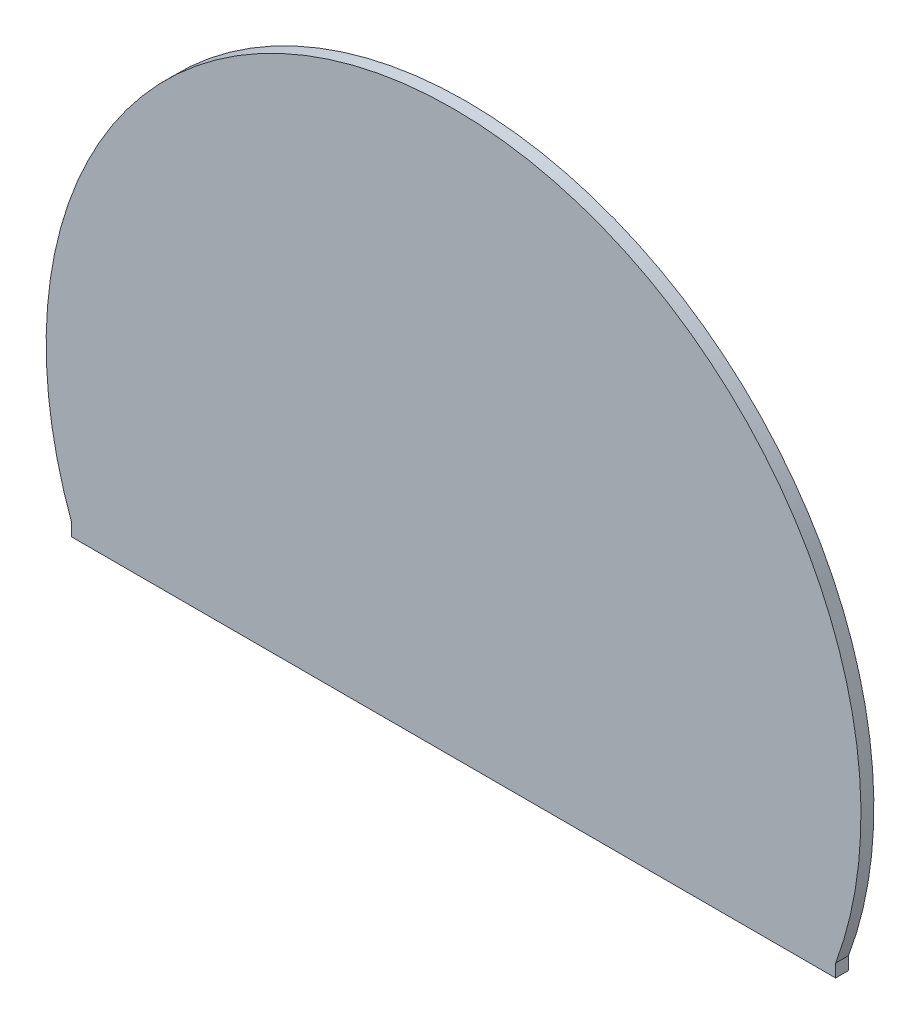
from build123d import *

# Parameters (mm, degrees)
BOSS_EXTRUDE1_DEPTH = 5


with BuildPart() as part:
    # Sketch1 → Boss-Extrude1 (new body)
    with BuildSketch(Plane.XY):
        with BuildLine():
            Line((148.338085742, -54.929954685), (148.338085742, -59.929954685))
            Line((148.338085742, -59.929954685), (-148.338085742, -59.929954685))
            Line((-148.338085742, -59.929954685), (-148.338085742, -54.929954685))
            ThreePointArc((-148.338085742, -54.929954685), (0, 158.181818182), (148.338085742, -54.929954685))
        make_face()
    extrude(amount=BOSS_EXTRUDE1_DEPTH)


solid = part.part
